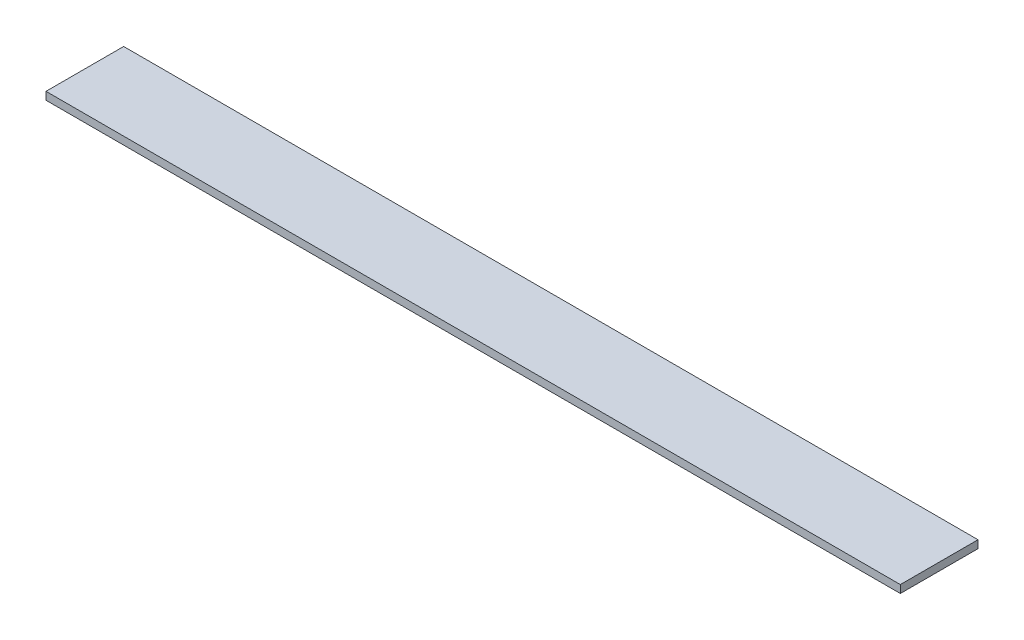
from build123d import *

# Parameters (mm, degrees)
ESQUISSE1_W      = 1100
ESQUISSE1_H      = 100
EXTRUSION1_DEPTH = 10


with BuildPart() as part:
    # Esquisse1 → Extrusion1 (new body)
    with BuildSketch(Plane(origin=(0, 0, 0), x_dir=(1, 0, 0), z_dir=(0, 1, 0))):
        with Locations((550, 50)):
            Rectangle(ESQUISSE1_W, ESQUISSE1_H)
    extrude(amount=EXTRUSION1_DEPTH)


solid = part.part
